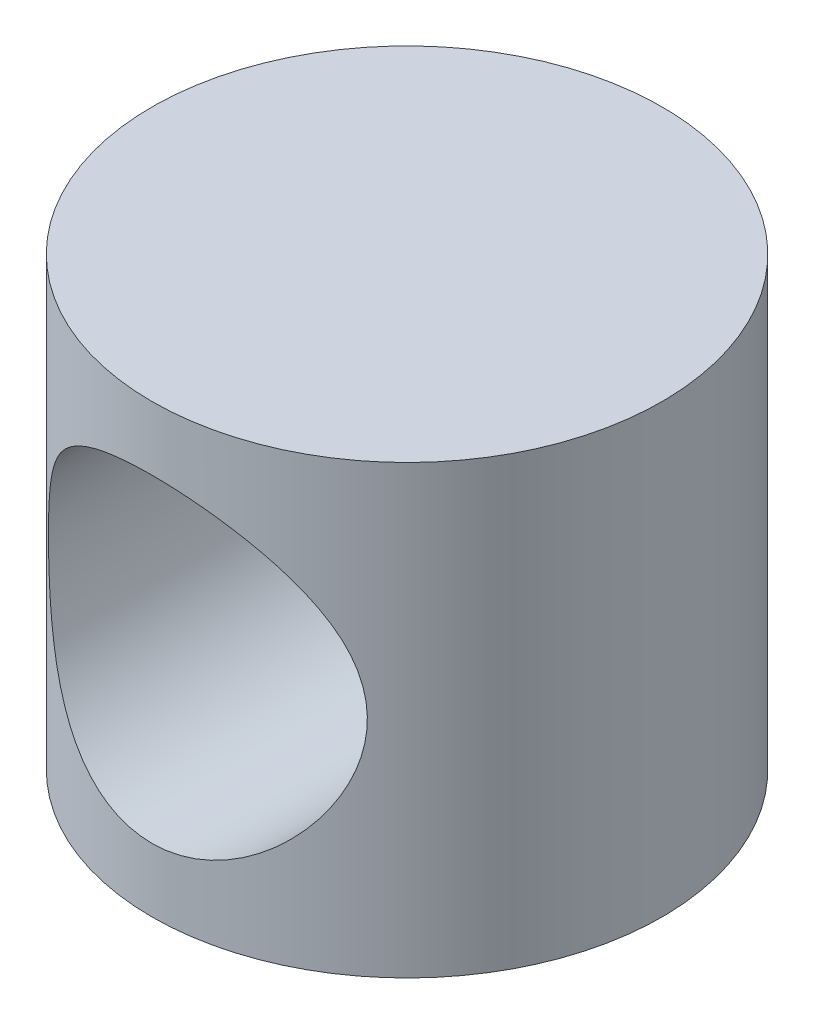
from build123d import *

# Parameters (mm, degrees)
SKETCH1_R               = 4
BOSS_EXTRUDE1_DEPTH     = 7
CUT_EXTRUDE1_DEPTH      = 7
CUT_EXTRUDE1_DEPTH_BACK = 7
SKETCH2_R               = 2.5


with BuildPart() as part:
    # Sketch1 → Boss-Extrude1 (new body)
    with BuildSketch(Plane(origin=(0, 0, 0), x_dir=(1, 0, 0), z_dir=(0, 1, 0))):
        Circle(SKETCH1_R)
    extrude(amount=BOSS_EXTRUDE1_DEPTH)

    # Sketch2 → Cut-Extrude1 (cut, two sides: drawn at the far end of the back side and taken through both)
    with BuildSketch(Plane.XY.offset(-CUT_EXTRUDE1_DEPTH_BACK)):
        with Locations((0, 3.5)):
            Circle(SKETCH2_R)
    extrude(amount=CUT_EXTRUDE1_DEPTH + CUT_EXTRUDE1_DEPTH_BACK, mode=Mode.SUBTRACT)


solid = part.part
